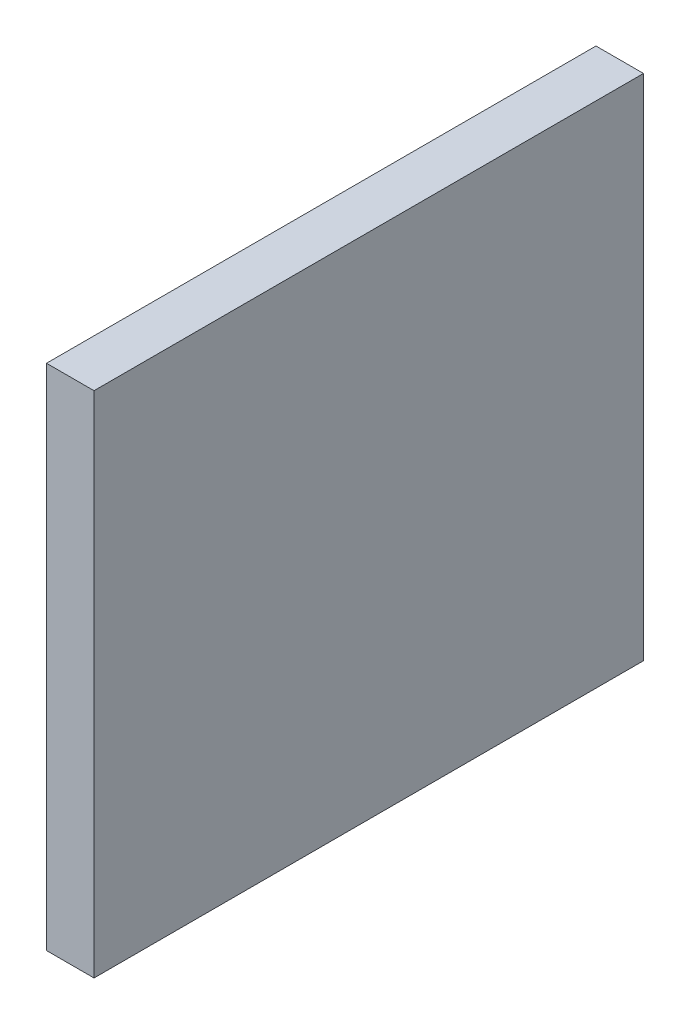
from build123d import *

# Parameters (mm, degrees)
SKETCH2_W           = 5
SKETCH2_H           = 53.502447605
BOSS_EXTRUDE1_DEPTH = 57.8


with BuildPart() as part:
    # Sketch2 → Boss-Extrude1 (new body)
    with BuildSketch(Plane.XY.offset(-331.8)):
        with Locations((-116.1, -26.751223803)):
            Rectangle(SKETCH2_W, SKETCH2_H)
    extrude(amount=BOSS_EXTRUDE1_DEPTH)


solid = part.part
